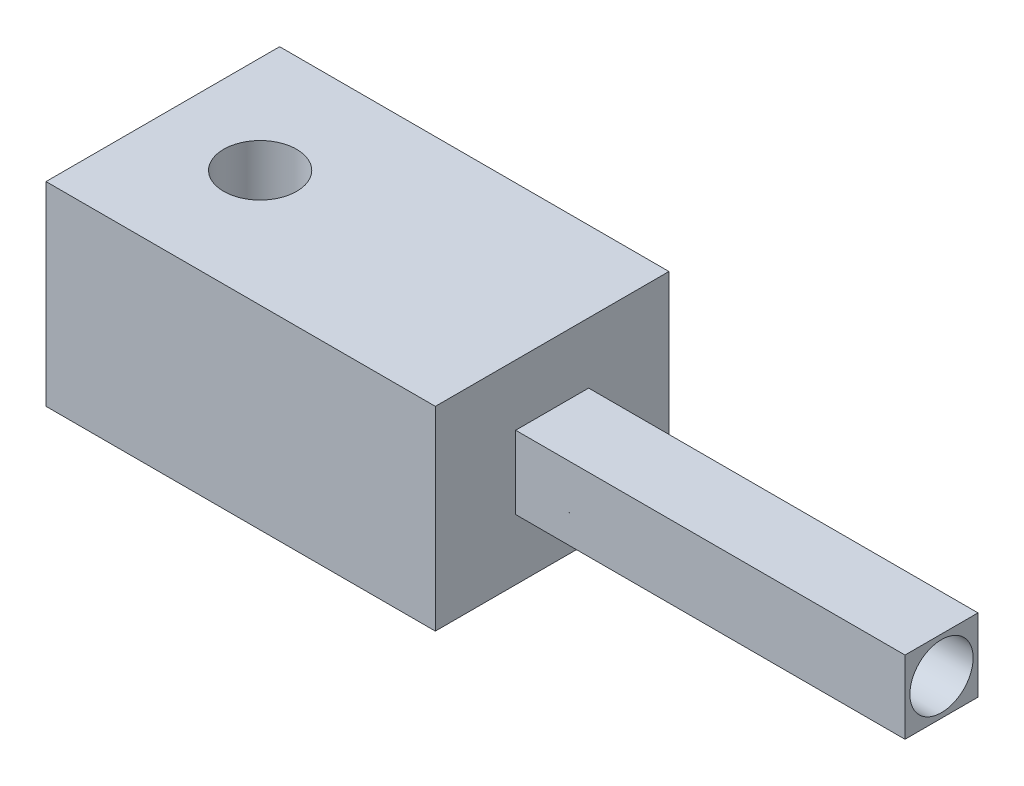
from build123d import *

# Parameters (mm, degrees)
SKETCH1_W           = 7.5
SKETCH1_H           = 7.5
BOSS_EXTRUDE1_DEPTH = 40
SKETCH2_W           = 24
SKETCH2_H           = 20
BOSS_EXTRUDE2_DEPTH = 40
SKETCH4_R           = 3.75
CUT_EXTRUDE1_DEPTH  = 20
SKETCH3_R           = 3.25
CUT_EXTRUDE2_DEPTH  = 40


with BuildPart() as part:
    # Sketch1 → Boss-Extrude1 (new body)
    with BuildSketch(Plane(origin=(0, 0, 0), x_dir=(0, 0, -1), z_dir=(1, 0, 0))):
        Rectangle(SKETCH1_W, SKETCH1_H)
    extrude(amount=BOSS_EXTRUDE1_DEPTH)

    # Sketch2 → Boss-Extrude2 (add)
    with BuildSketch(Plane.ZY):
        Rectangle(SKETCH2_W, SKETCH2_H)
    extrude(amount=BOSS_EXTRUDE2_DEPTH)

    # Sketch4 → Cut-Extrude1 (cut)
    with BuildSketch(Plane(origin=(0, 10, 0), x_dir=(1, 0, 0), z_dir=(0, 1, 0))):
        with Locations((-30, 0)):
            Circle(SKETCH4_R)
    extrude(amount=-CUT_EXTRUDE1_DEPTH, mode=Mode.SUBTRACT)

    # Sketch3 → Cut-Extrude2 (cut)
    with BuildSketch(Plane(origin=(40, 0, 0), x_dir=(0, 0, -1), z_dir=(1, 0, 0))):
        Circle(SKETCH3_R)
    extrude(amount=-CUT_EXTRUDE2_DEPTH, mode=Mode.SUBTRACT)


solid = part.part
